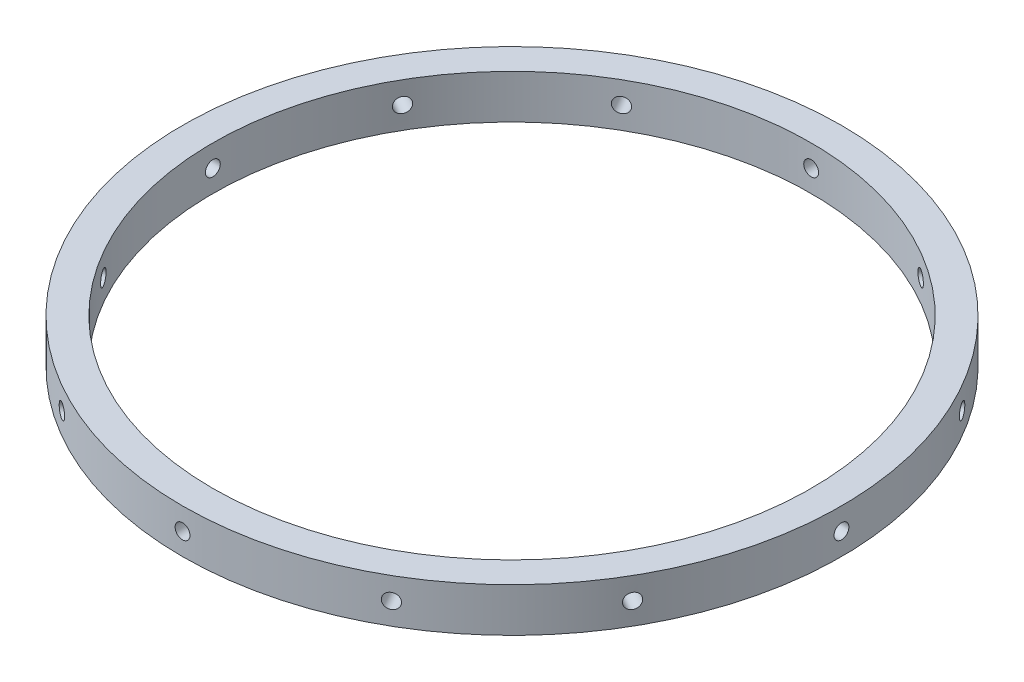
from build123d import *

# Parameters (mm, degrees)
SKETCH1_R           = 95.25
SKETCH1_R_2         = 86.487
BOSS_EXTRUDE1_DEPTH = 12.7
SKETCH3_R           = 2.1463
CUT_EXTRUDE2_DEPTH  = 254
CIRPATTERN1_COUNT   = 12


with BuildPart() as part:
    # Sketch1 → Boss-Extrude1 (new body)
    with BuildSketch(Plane(origin=(0, 0, 0), x_dir=(1, 0, 0), z_dir=(0, 1, 0))):
        Circle(SKETCH1_R)
        Circle(SKETCH1_R_2, mode=Mode.SUBTRACT)
    extrude(amount=BOSS_EXTRUDE1_DEPTH)

    # Sketch3 → Cut-Extrude2 (cut)
    with BuildSketch(Plane.XY):
        with Locations((0, 6.35)):
            Circle(SKETCH3_R)
    cut_extrude2 = extrude(amount=-CUT_EXTRUDE2_DEPTH, mode=Mode.SUBTRACT)

    # CirPattern1: Cut-Extrude2 ×12 about axis
    cirpattern1_axis = Axis((0, 12.7, 0), (0, 1, 0))
    for i in range(1, CIRPATTERN1_COUNT):
        add(cut_extrude2.rotate(cirpattern1_axis, i * 360 / CIRPATTERN1_COUNT), mode=Mode.SUBTRACT)


solid = part.part
